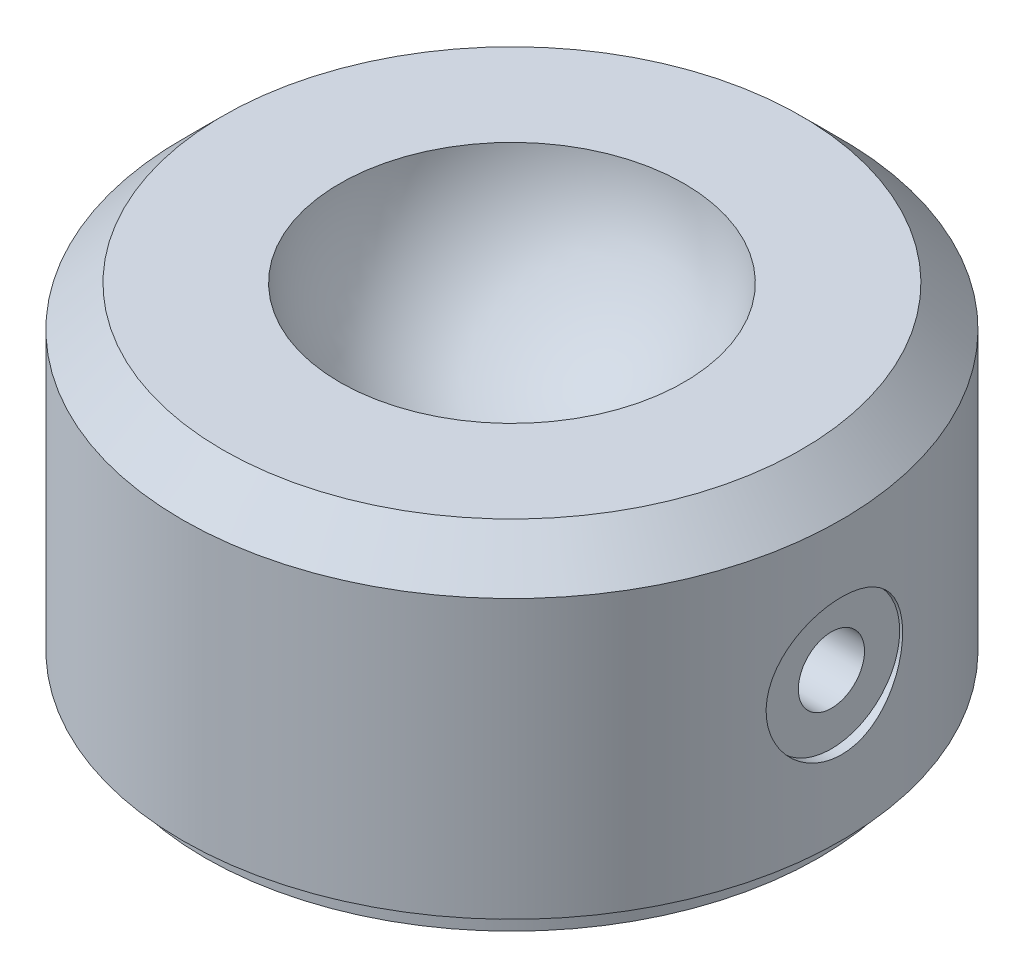
from build123d import *

# Parameters (mm, degrees)
SKETCH1_R                          = 12.446
EXTRUDE1_DEPTH                     = 6.0071
CHAMFER1_SIZE                      = 1.524
SKETCH2_R                          = 11.5951
EXTRUDE2_DEPTH                     = 0.99076
SKETCH3_R                          = 1.5875
EXTRUDE3_DEPTH                     = 6.3754
F_5_16_0_3125_DIAMETER_HOLE2_D     = 5.1562
F_5_16_0_3125_DIAMETER_HOLE2_DEPTH = 0.381
M3X0_5_TAPPED_HOLE1_D              = 2.5
M3X0_5_TAPPED_HOLE1_DEPTH          = 5.3086
M3X0_5_TAPPED_HOLE1_TIP            = 0.751075774


with BuildPart() as part:
    # Sketch1 → Extrude1 (new body, symmetric)
    with BuildSketch(Plane(origin=(0, 0, 0), x_dir=(1, 0, 0), z_dir=(0, 1, 0))):
        Circle(SKETCH1_R)
    extrude(amount=EXTRUDE1_DEPTH, both=True)

    # Chamfer1
    chamfer1_edges = [part.edges().sort_by_distance(p)[0] for p in [
        (-12.446, 6.0071, 0),
    ]]
    chamfer(chamfer1_edges, length=CHAMFER1_SIZE)

    # Sketch2 → Extrude2 (add)
    with BuildSketch(Plane.XZ.offset(6.0071)):
        Circle(SKETCH2_R)
    extrude(amount=EXTRUDE2_DEPTH)

    # Sketch3 → Extrude3 (cut)
    with BuildSketch(Plane(origin=(0, 6.0071, 0), x_dir=(1, 0, 0), z_dir=(0, 1, 0))):
        Circle(SKETCH3_R)
    extrude(amount=-EXTRUDE3_DEPTH, mode=Mode.SUBTRACT)

    # Sketch4 → Cut-Revolve1 (revolve, cut)
    with BuildSketch(Plane.XY):
        with BuildLine():
            Line((0, 13.035099954), (0, -0.004899954))
            ThreePointArc((0, -0.004899954), (6.519999954, 6.5151), (0, 13.035099954))
        make_face()
    revolve(axis=Axis((0, 13.035099954, 0), (0, -1, 0)), mode=Mode.SUBTRACT)

    # 5/16 (0.3125) Diameter Hole2
    with Locations(Plane(origin=(12.446, 0, 0), x_dir=(0, 0, -1), z_dir=(1, 0, 0))):
        with Locations((0, -0.6223)):
            Hole(F_5_16_0_3125_DIAMETER_HOLE2_D / 2, depth=F_5_16_0_3125_DIAMETER_HOLE2_DEPTH)

    # M3x0.5 Tapped Hole1
    with Locations(Plane(origin=(12.065, 0, 0), x_dir=(0, 0, -1), z_dir=(1, 0, 0))):
        with Locations((0, -0.6223)):
            Hole(M3X0_5_TAPPED_HOLE1_D / 2, depth=M3X0_5_TAPPED_HOLE1_DEPTH)
            with Locations((0, 0, -(M3X0_5_TAPPED_HOLE1_DEPTH + M3X0_5_TAPPED_HOLE1_TIP / 2))):  # 118° drill point
                Cone(0, M3X0_5_TAPPED_HOLE1_D / 2, M3X0_5_TAPPED_HOLE1_TIP, mode=Mode.SUBTRACT)


solid = part.part
